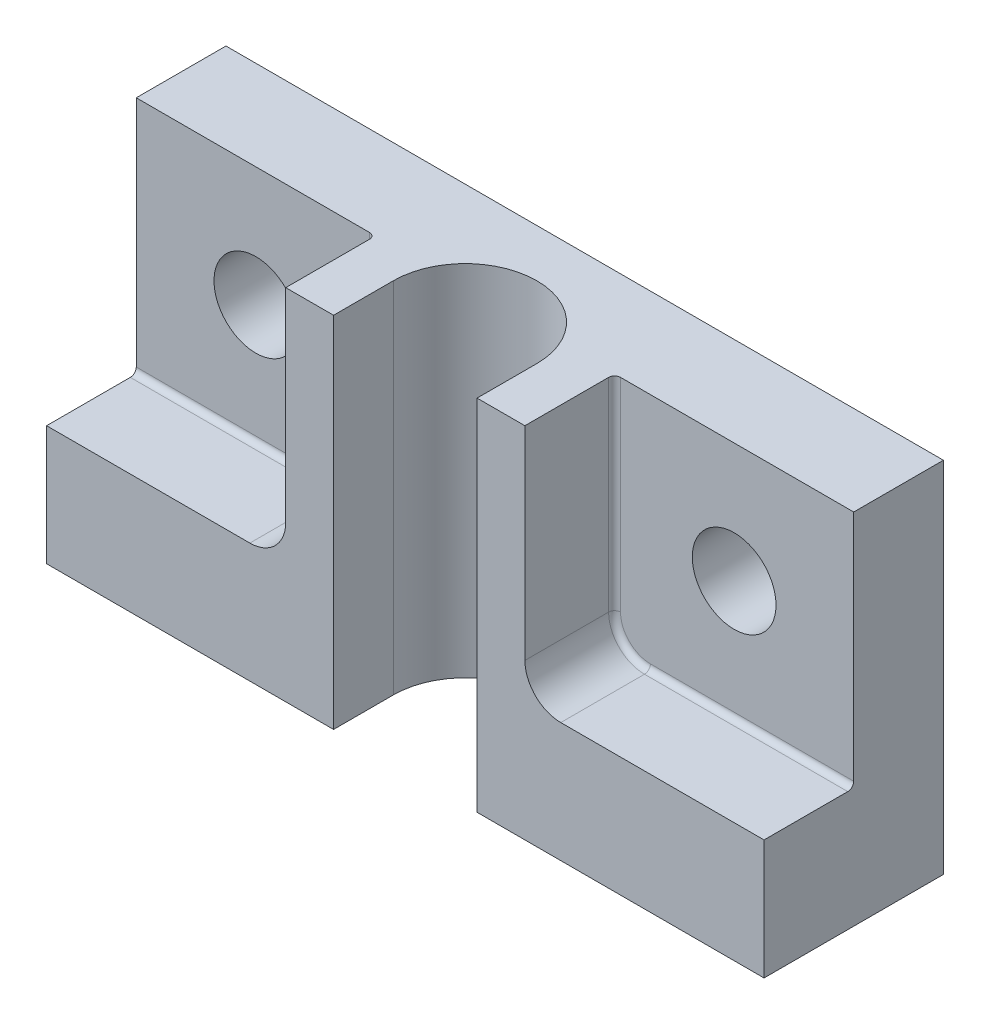
from build123d import *

# Parameters (mm, degrees)
SKETCH1_W      = 60
SKETCH1_H      = 30
SKETCH1_R      = 3.5
EXTRUDE1_DEPTH = 15
EXTRUDE2_DEPTH = 7.5
EXTRUDE3_DEPTH = 31
FILLET1_R      = 0.5


with BuildPart() as part:
    # Sketch1 → Extrude1 (new body)
    with BuildSketch(Plane.XY):
        with Locations((0, -15)):
            Rectangle(SKETCH1_W, SKETCH1_H)
        with Locations((20, -10)):
            Circle(SKETCH1_R, mode=Mode.SUBTRACT)
        with Locations((-20, -10)):
            Circle(SKETCH1_R, mode=Mode.SUBTRACT)
    extrude(amount=-EXTRUDE1_DEPTH)

    # Sketch2 → Extrude2 (cut)
    with BuildSketch(Plane.XY):
        with BuildLine():
            Line((13, -20), (30, -20))
            Line((30, -20), (30, 0))
            Line((30, 0), (10, 0))
            Line((10, 0), (10, -17))
            ThreePointArc((10, -17), (10.878679656, -19.121320344), (13, -20))
        make_face()
        with BuildLine():
            Line((-30, -20), (-30, 0))
            Line((-30, 0), (-10, 0))
            Line((-10, 0), (-10, -17))
            ThreePointArc((-10, -17), (-10.878679656, -19.121320344), (-13, -20))
            Line((-13, -20), (-30, -20))
        make_face()
    extrude(amount=-EXTRUDE2_DEPTH, mode=Mode.SUBTRACT)

    # Sketch3 → Extrude3 (cut, through all)
    with BuildSketch(Plane(origin=(0, 0, 0), x_dir=(1, 0, 0), z_dir=(0, 1, 0))):
        with BuildLine():
            Line((6, 0), (6, 5))
            ThreePointArc((6, 5), (0, 11), (-6, 5))
            Line((-6, 5), (-6, 0))
            Line((-6, 0), (6, 0))
        make_face()
    extrude(amount=-EXTRUDE3_DEPTH, mode=Mode.SUBTRACT)

    # Fillet1
    fillet1_edges = [part.edges().sort_by_distance(p)[0] for p in [
        (21.5, -20, -7.5),
        (10.878679656, -19.121320344, -7.5),
        (10, -8.5, -7.5),
        (-10.878679656, -19.121320344, -7.5),
        (-21.5, -20, -7.5),
        (-10, -8.5, -7.5),
    ]]
    fillet(fillet1_edges, radius=FILLET1_R)


solid = part.part
